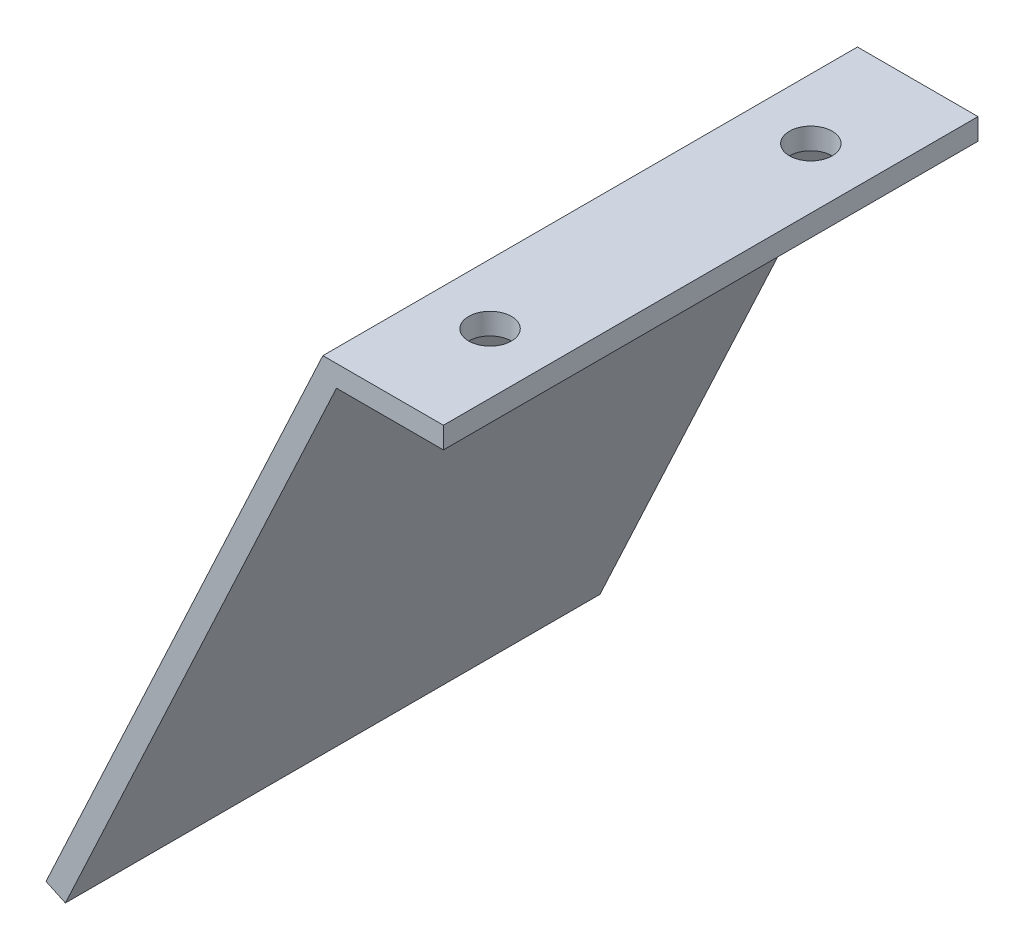
from build123d import *

# Parameters (mm, degrees)
BOSS_EXTRUDE1_DEPTH = 50
CUT_EXTRUDE1_REACH  = 58.378
SKETCH2_R           = 2


with BuildPart() as part:
    # Sketch1 → Boss-Extrude1 (new body)
    with BuildSketch(Plane.XY):
        Polygon((0, 0), (-10, 0), (-35.357095704, -54.378467222), (-37.169711279, -53.533230699), (-11.274140522, 2), (0, 2), align=None)
    extrude(amount=BOSS_EXTRUDE1_DEPTH)

    # Sketch2 → Cut-Extrude1 (cut, up to next)
    with BuildSketch(Plane(origin=(0, 2, 0), x_dir=(1, 0, 0), z_dir=(0, 1, 0)), mode=Mode.PRIVATE) as cut_extrude1_sk1:
        with Locations((-5.637070261, -10)):
            Circle(SKETCH2_R)
    cut_extrude1_tool1 = extrude(cut_extrude1_sk1.sketch, amount=-CUT_EXTRUDE1_REACH, mode=Mode.PRIVATE) & part.part
    add(cut_extrude1_tool1.solids().sort_by_distance((-5.63707, 2, 10))[0], mode=Mode.SUBTRACT)
    # Sketch2 → Cut-Extrude1 (cut, up to next)
    with BuildSketch(Plane(origin=(0, 2, 0), x_dir=(1, 0, 0), z_dir=(0, 1, 0)), mode=Mode.PRIVATE) as cut_extrude1_sk2:
        with Locations((-5.637070261, -40)):
            Circle(SKETCH2_R)
    cut_extrude1_tool2 = extrude(cut_extrude1_sk2.sketch, amount=-CUT_EXTRUDE1_REACH, mode=Mode.PRIVATE) & part.part
    add(cut_extrude1_tool2.solids().sort_by_distance((-5.63707, 2, 40))[0], mode=Mode.SUBTRACT)


solid = part.part
